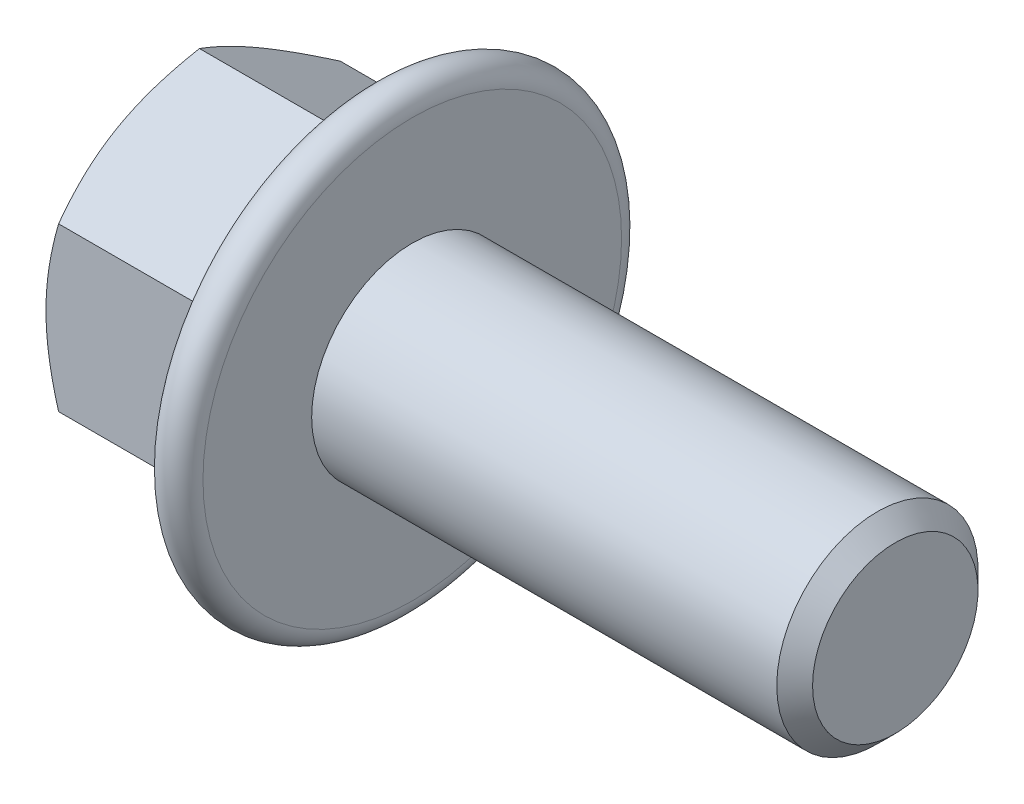
from build123d import *

# Parameters (mm, degrees)
BASEHEAD_DEPTH    = 5.6
FLANGEHEXFILLET_R = 0.1


with BuildPart() as part:
    # Sketch1 → BaseHead (new body)
    with BuildSketch(Plane(origin=(0, 0, 0), x_dir=(0, 0, -1), z_dir=(1, 0, 0))):
        Polygon((3.5, 2.020725942), (3.5, -2.020725942), (0, -4.041451884), (-3.5, -2.020725942), (-3.5, 2.020725942), (0, 4.041451884), align=None)
    extrude(amount=BASEHEAD_DEPTH)

    # BodySke → BaseBody (revolve)
    with BuildSketch(Plane.XY, mode=Mode.PRIVATE) as basebody_sk:
        Polygon((0, 0), (17.6, 0), (17.6, 2.055), (17.155, 2.5), (0, 2.5), align=None)
    revolve(basebody_sk.sketch.rotate(Axis((0, 0, 0), (1, 0, 0)), 90), axis=Axis((0, 0, 0), (1, 0, 0)))

    # Sketch3 → HeadChamfer (revolve, cut)
    with BuildSketch(Plane.XY, mode=Mode.PRIVATE) as headchamfer_sk:
        Polygon((0, 3.5), (3.199358737, 9.041451884), (3.199358737, 14.041451884), (-10, 14.041451884), (-10, 3.5), align=None)
    revolve(headchamfer_sk.sketch.rotate(Axis((0, 0, 0), (1, 0, 0)), 90), axis=Axis((0, 0, 0), (1, 0, 0)), mode=Mode.SUBTRACT)

    # Sketch4 → Flange (revolve)
    with BuildSketch(Plane.XY, mode=Mode.PRIVATE) as flange_sk:
        with BuildLine():
            Line((2.675265896, 0), (4.63015369, 5.371010072))
            ThreePointArc((4.63015369, 5.371010072), (5.186824089, 5.692403877), (5.6, 5.2))
            Line((5.6, 5.2), (5.6, 0))
            Line((5.6, 0), (2.675265896, 0))
        make_face()
    revolve(flange_sk.sketch.rotate(Axis((0, 0, 0), (1, 0, 0)), 90), axis=Axis((0, 0, 0), (1, 0, 0)))

    # FlangeHexFillet
    flangehexfillet_edges = [part.edges().sort_by_distance(p)[0] for p in [
        (3.949161716, 0, -3.5),
        (3.949161716, -3.031088913, -1.75),
        (4.001624527, 1.014770503, 3.5),
        (3.949161716, 3.031088913, 1.75),
        (3.949161716, 3.031088913, -1.75),
        (3.949161716, -3.031088913, 1.75),
        (4.001624527, -1.014770503, 3.5),
    ]]
    fillet(flangehexfillet_edges, radius=FLANGEHEXFILLET_R)


solid = part.part
